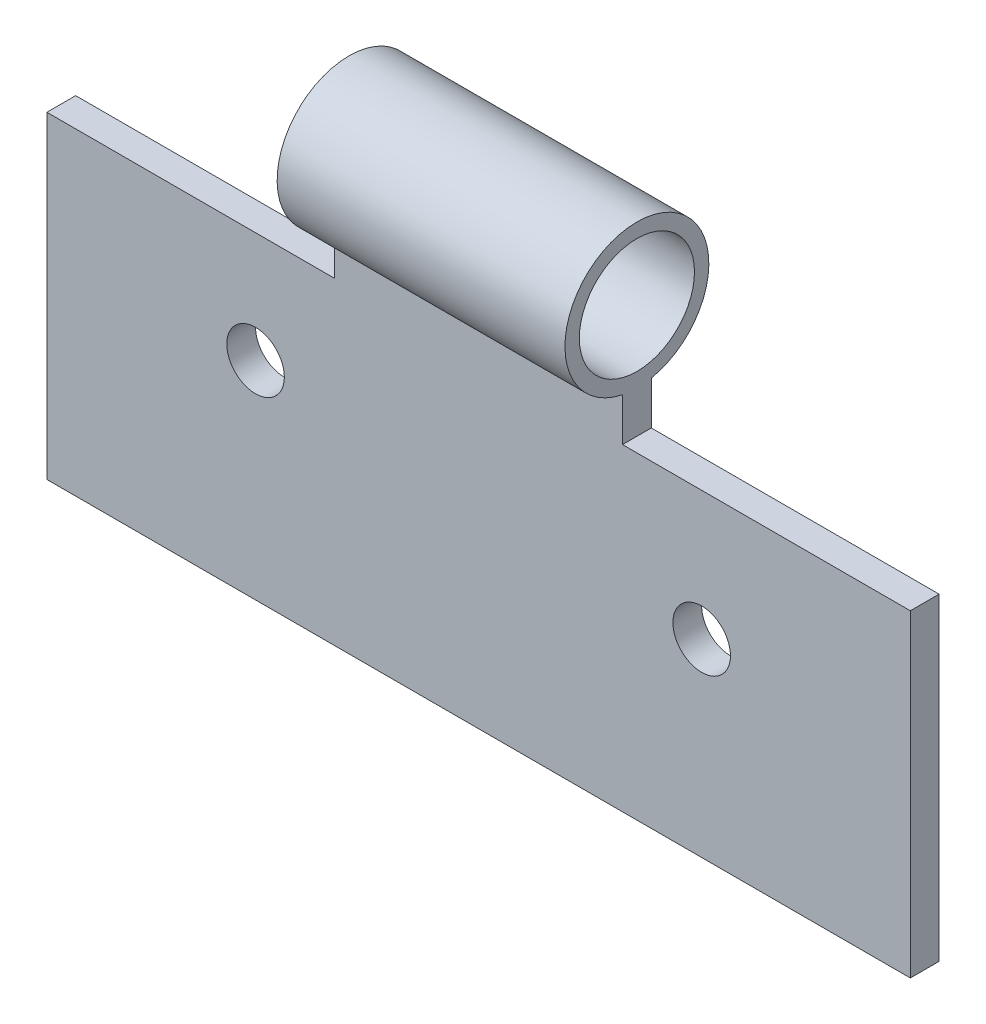
from build123d import *

# Parameters (mm, degrees)
SKETCH_2_R               = 0.2
EXTRUDE_1_DEPTH          = 3
CUT_EXTRUDE_1_DEPTH      = 3
CUT_EXTRUDE_1_DEPTH_BACK = 3
SKETCH_3_W               = 1
SKETCH_3_H               = 1.471690569
SKETCH_4_R               = 0.1
CUT_EXTRUDE_2_DEPTH      = 3


with BuildPart() as part:
    # 草图2 → 凸台-拉伸1 (new body)
    with BuildSketch(Plane(origin=(0, 0, 0), x_dir=(0, 0, -1), z_dir=(1, 0, 0))):
        with BuildLine():
            Line((0, -0.75), (0.1, -0.75))
            Line((0.1, -0.75), (0.1, 0.505051026))
            ThreePointArc((0.1, 0.505051026), (0.05, 1), (0, 0.505051026))
            Line((0, 0.505051026), (0, -0.75))
        make_face()
        with Locations((0.05, 0.75)):
            Circle(SKETCH_2_R, mode=Mode.SUBTRACT)
    extrude(amount=EXTRUDE_1_DEPTH)

    # 草图3 → 切除-拉伸1 (cut, two sides: drawn at the far end of the back side and taken through both)
    with BuildSketch(Plane(origin=(0, 0, -0.1), x_dir=(-1, 0, 0), z_dir=(0, 0, -1)).offset(-CUT_EXTRUDE_1_DEPTH_BACK)):
        with Locations((-2.5, 1.090896311)):
            Rectangle(SKETCH_3_W, SKETCH_3_H)
        with Locations((-0.5, 1.090896311)):
            Rectangle(SKETCH_3_W, SKETCH_3_H)
    extrude(amount=CUT_EXTRUDE_1_DEPTH + CUT_EXTRUDE_1_DEPTH_BACK, mode=Mode.SUBTRACT)

    # 草图4 → 切除-拉伸2 (cut)
    with BuildSketch(Plane.XY):
        with Locations((0.725, -0.029598001)):
            Circle(SKETCH_4_R)
        with Locations((2.275, -0.092876486)):
            Circle(SKETCH_4_R)
    extrude(amount=-CUT_EXTRUDE_2_DEPTH, mode=Mode.SUBTRACT)


solid = part.part
